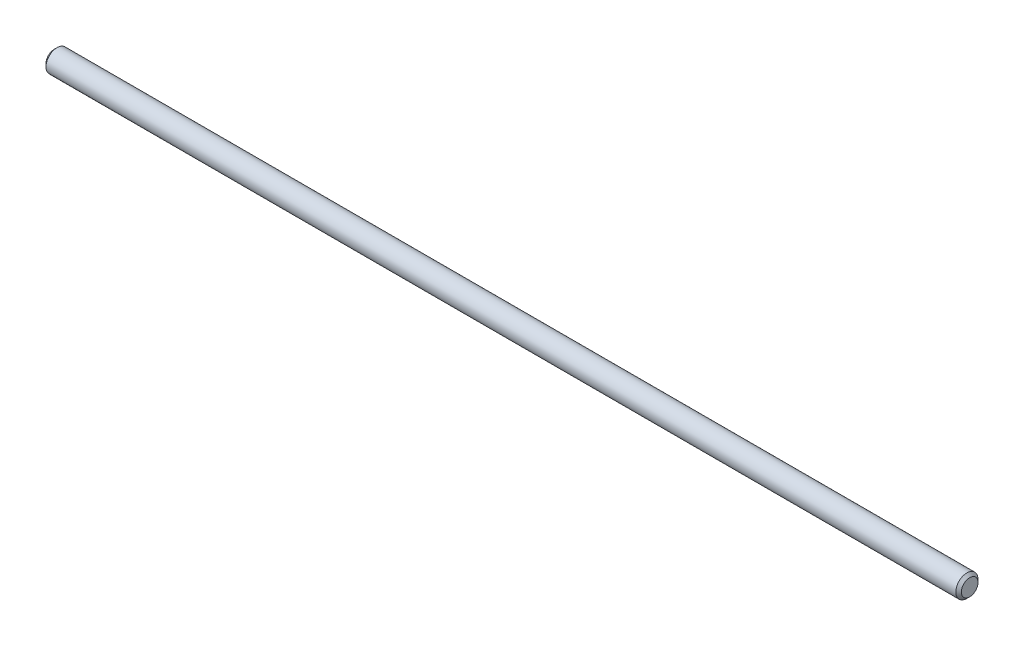
from build123d import *

# Parameters (mm, degrees)
CROQUIS1_R              = 4
SALIENTE_EXTRUIR1_DEPTH = 165
CHAFL_N1_SIZE           = 1


with BuildPart() as part:
    # Croquis1 → Saliente-Extruir1 (new body, symmetric)
    with BuildSketch(Plane(origin=(0, 0, 0), x_dir=(0, 0, -1), z_dir=(1, 0, 0))):
        Circle(CROQUIS1_R)
    extrude(amount=SALIENTE_EXTRUIR1_DEPTH, both=True)

    # Chaflán1
    chafl_n1_edges = [part.edges().sort_by_distance(p)[0] for p in [
        (-165, 0, 4),
        (165, 0, 4),
    ]]
    chamfer(chafl_n1_edges, length=CHAFL_N1_SIZE)


solid = part.part
